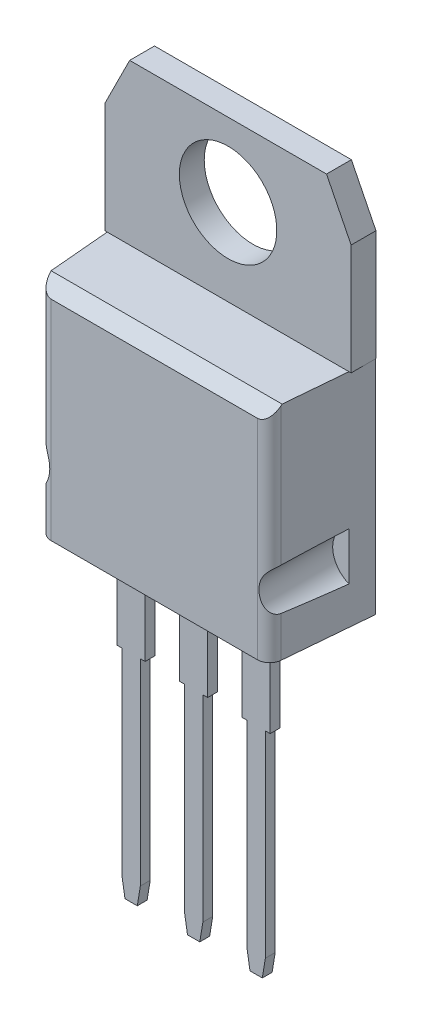
from build123d import *

# Parameters (mm, degrees)
SKETCH2_W                = 10
SKETCH2_H                = 9
BOSS_EXTRUDE1_DEPTH      = 4
CHAMFER1_SIZE            = 0.5
CUT_EXTRUDE1_DEPTH       = 3
BOSS_EXTRUDE2_DEPTH      = 0.4
LPATTERN1_COUNT          = 2
LPATTERN1_PITCH          = 2.54
LPATTERN2_COUNT          = 2
LPATTERN2_PITCH          = 2.54
DRAFT2_ANGLE             = -5
SKETCH8_R                = 1.98
BOSS_EXTRUDE3_DEPTH      = 0.01
BOSS_EXTRUDE3_DEPTH_BACK = 1
FILLET1_R                = 0.5


with BuildPart() as part:
    # Sketch2 → Boss-Extrude1 (new body)
    with BuildSketch(Plane.XY):
        Rectangle(SKETCH2_W, SKETCH2_H)
    extrude(amount=BOSS_EXTRUDE1_DEPTH)

    # Chamfer1
    chamfer1_edges = [part.edges().sort_by_distance(p)[0] for p in [
        (0, 4.5, 4),
    ]]
    chamfer(chamfer1_edges, length=CHAMFER1_SIZE)

    # Sketch6 → Cut-Extrude1 (cut)
    with BuildSketch(Plane.XY.offset(4)):
        with BuildLine():
            Line((5, -1), (5, -3))
            ThreePointArc((5, -3), (4.25, -2), (5, -1))
        make_face()
    cut_extrude1 = extrude(amount=-CUT_EXTRUDE1_DEPTH, mode=Mode.SUBTRACT)

    # Mirror1: Cut-Extrude1 across plane
    add(cut_extrude1.mirror(Plane(origin=(0, 0, 0), x_dir=(0, 0, 1), z_dir=(1, 0, 0))), mode=Mode.SUBTRACT)

    # Sketch7 → Boss-Extrude2 (add)
    with BuildSketch(Plane.XY.offset(2)):
        Polygon((-0.57, -4.5), (-0.57, -8.44), (-0.375, -8.44), (-0.375, -16.44), (-0.25, -17.2), (0.25, -17.2), (0.375, -16.44), (0.375, -8.44), (0.57, -8.44), (0.57, -4.5), align=None)
    boss_extrude2 = extrude(amount=BOSS_EXTRUDE2_DEPTH)

    # LPattern1: Boss-Extrude2 ×2
    with Locations(*[(-i * LPATTERN1_PITCH, 0, 0) for i in range(1, LPATTERN1_COUNT)]):
        add(boss_extrude2)

    # LPattern2: Boss-Extrude2 ×2
    with Locations(*[(i * LPATTERN2_PITCH, 0, 0) for i in range(1, LPATTERN2_COUNT)]):
        add(boss_extrude2)

    # Draft2
    draft2_faces = [part.faces().sort_by_distance(p)[0] for p in [
        (5, 0.383542538, 1.891910739),
        (-5, 0.383542538, 1.891910739),
    ]]
    draft(draft2_faces, Plane(origin=(0, 0, 0), x_dir=(-1, 0, 0), z_dir=(0, 0, -1)), DRAFT2_ANGLE)

    # Sketch8 → Boss-Extrude3 (add, two sides)
    with BuildSketch(Plane(origin=(0, 0, 0), x_dir=(-1, 0, 0), z_dir=(0, 0, -1))) as boss_extrude3_sk:
        Polygon((-5, 9), (-4, 11), (4, 11), (5, 9), (5, 4.5), (-5, 4.5), align=None)
        with Locations((0, 8)):
            Circle(SKETCH8_R, mode=Mode.SUBTRACT)
    extrude(amount=BOSS_EXTRUDE3_DEPTH)
    extrude(boss_extrude3_sk.sketch, amount=-BOSS_EXTRUDE3_DEPTH_BACK)

    # Fillet1
    fillet1_edges = [part.edges().sort_by_distance(p)[0] for p in [
        (-4.650045346, 1.410302183, 4),
        (4.650045346, 1.410302183, 4),
    ]]
    fillet(fillet1_edges, radius=FILLET1_R)


solid = part.part
